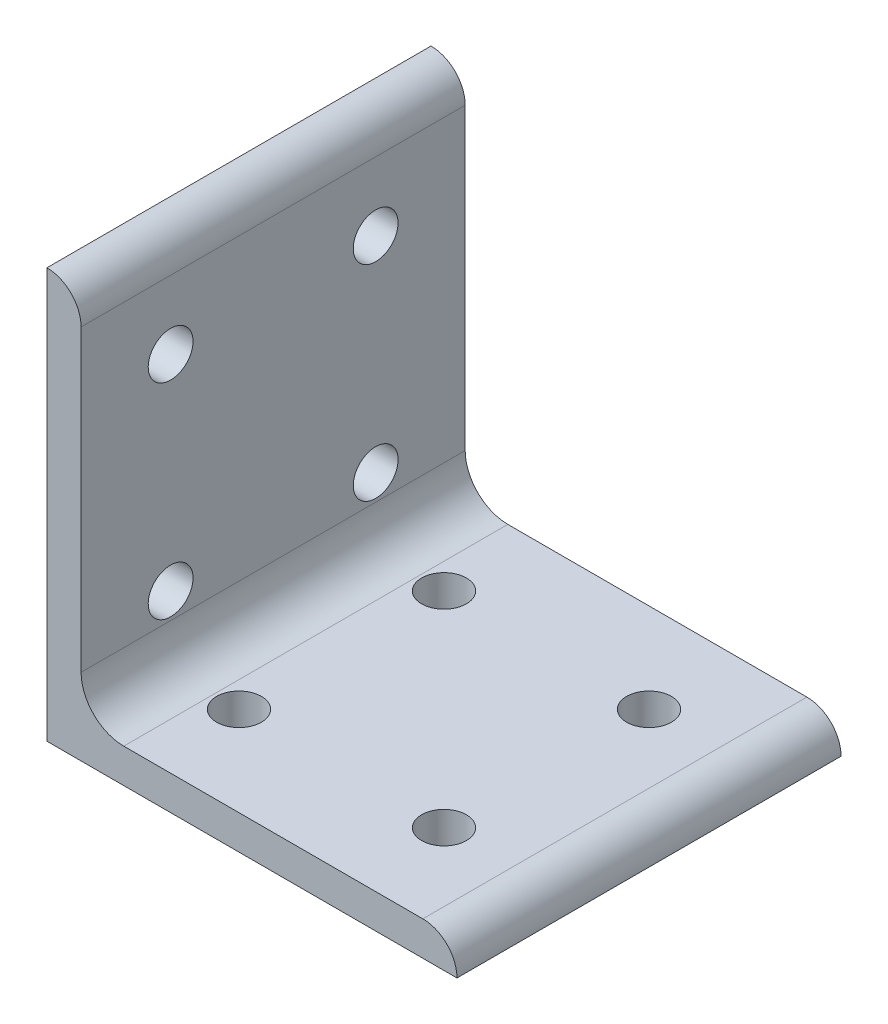
from build123d import *

# Parameters (mm, degrees)
BOSS_EXTRUDE1_DEPTH = 35.687
SKETCH2_R           = 4.1656
CUT_EXTRUDE1_DEPTH  = 77.2
SKETCH3_R           = 4.1656
CUT_EXTRUDE2_DEPTH  = 77.2


with BuildPart() as part:
    # Sketch1 → Boss-Extrude1 (new body, symmetric)
    with BuildSketch(Plane.XY):
        with BuildLine():
            Line((0, 0), (0, 76.2))
            ThreePointArc((0, 76.2), (4.490128061, 74.340128061), (6.35, 69.85))
            Line((6.35, 69.85), (6.35, 14.2748))
            ThreePointArc((6.35, 14.2748), (8.67112018, 8.67112018), (14.2748, 6.35))
            Line((14.2748, 6.35), (69.85, 6.35))
            ThreePointArc((69.85, 6.35), (74.340128061, 4.490128061), (76.2, 0))
            Line((76.2, 0), (0, 0))
        make_face()
    extrude(amount=BOSS_EXTRUDE1_DEPTH, both=True)

    # Sketch2 → Cut-Extrude1 (cut, through all)
    with BuildSketch(Plane(origin=(0, 0, 0), x_dir=(1, 0, 0), z_dir=(0, 1, 0))):
        with Locations((19.05, -19.05)):
            Circle(SKETCH2_R)
        with Locations((57.15, -19.05)):
            Circle(SKETCH2_R)
        with Locations((19.05, 19.05)):
            Circle(SKETCH2_R)
        with Locations((57.15, 19.05)):
            Circle(SKETCH2_R)
    extrude(amount=CUT_EXTRUDE1_DEPTH, mode=Mode.SUBTRACT)

    # Sketch3 → Cut-Extrude2 (cut, through all)
    with BuildSketch(Plane(origin=(0, 0, 0), x_dir=(0, 0, -1), z_dir=(1, 0, 0))):
        with Locations((-19.05, 19.05)):
            Circle(SKETCH3_R)
        with Locations((-19.05, 57.15)):
            Circle(SKETCH3_R)
        with Locations((19.05, 19.05)):
            Circle(SKETCH3_R)
        with Locations((19.05, 57.15)):
            Circle(SKETCH3_R)
    extrude(amount=CUT_EXTRUDE2_DEPTH, mode=Mode.SUBTRACT)


solid = part.part
